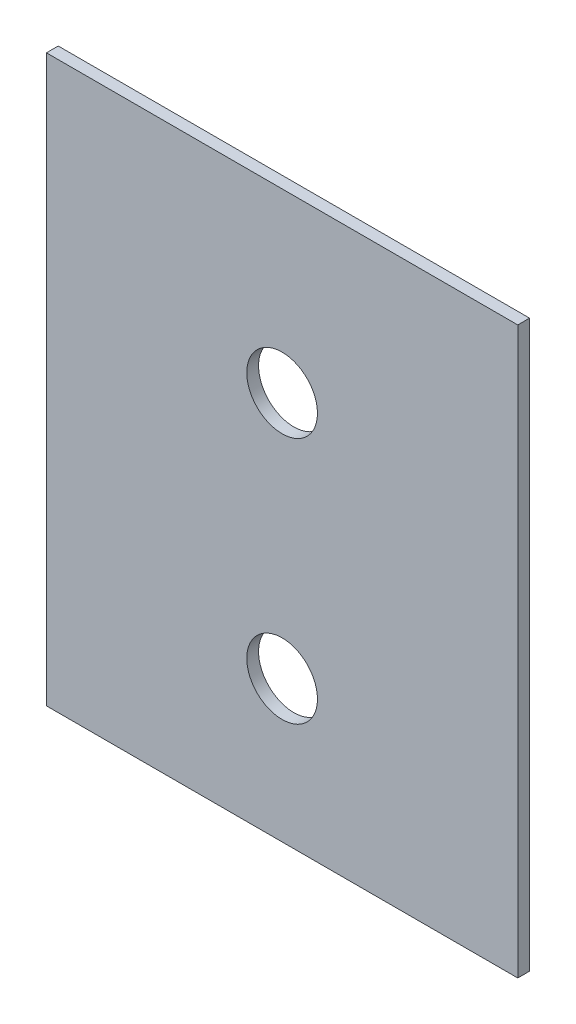
from build123d import *

# Parameters (mm, degrees)
SKETCH1_W      = 400
SKETCH1_H      = 480
SKETCH1_R      = 30
EXTRUDE1_DEPTH = 10


with BuildPart() as part:
    # Sketch1 → Extrude1 (new body)
    with BuildSketch(Plane.XY):
        with Locations((200, 240)):
            Rectangle(SKETCH1_W, SKETCH1_H)
        with Locations((200, 330)):
            Circle(SKETCH1_R, mode=Mode.SUBTRACT)
        with Locations((200, 120)):
            Circle(SKETCH1_R, mode=Mode.SUBTRACT)
    extrude(amount=EXTRUDE1_DEPTH)


solid = part.part
